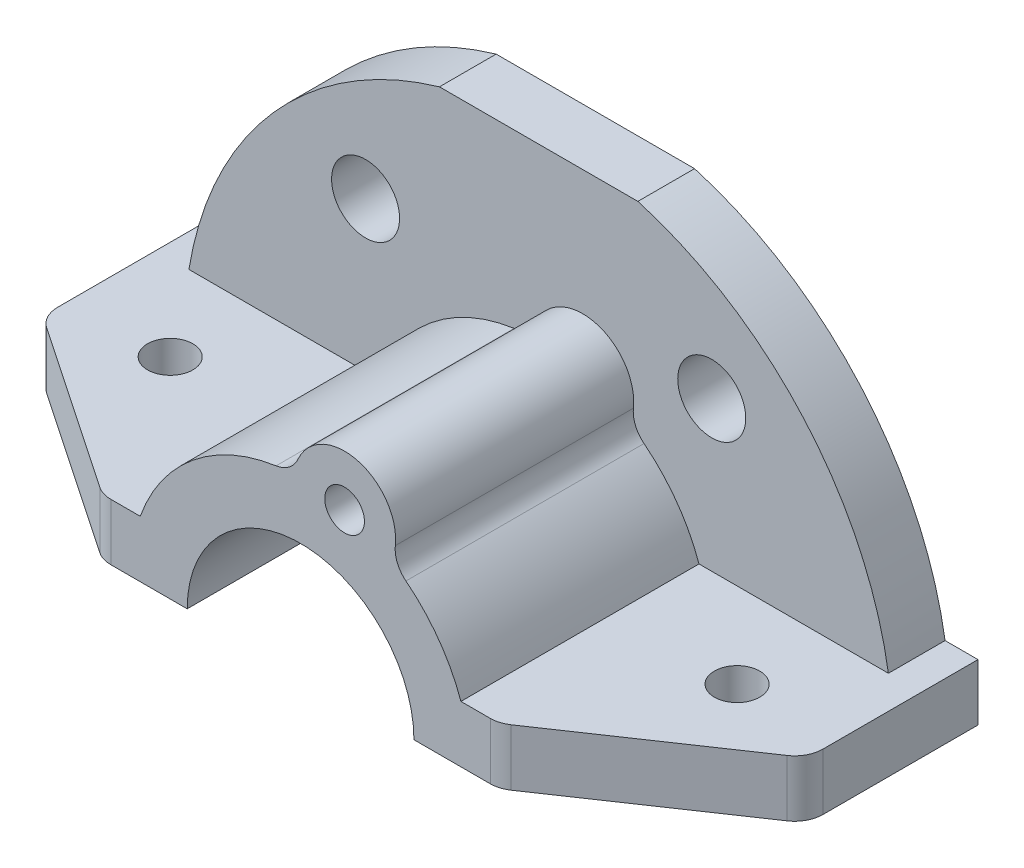
from build123d import *

# Parameters (mm, degrees)
SKETCH2_R           = 4
BOSS_EXTRUDE1_DEPTH = 10
CUT_EXTRUDE1_DEPTH  = 86.791899384
SKETCH3_3_R         = 3.5
BOSS_EXTRUDE2_DEPTH = 52
SKETCH4_R           = 3.5
SKETCH4_R_2         = 6
BOSS_EXTRUDE3_DEPTH = 10
FILLET1_R           = 5


with BuildPart() as part:
    # Sketch2 → Boss-Extrude1 (new body)
    with BuildSketch(Plane(origin=(0, 0, 0), x_dir=(1, 0, 0), z_dir=(0, 1, 0))):
        Polygon((-67.5, 26), (-67.5, -4), (-35, -26), (35, -26), (67.5, -4), (67.5, 26), align=None)
        with Locations(Location((-50, 1, 0), (0, 0, 270))):
            Circle(SKETCH2_R, mode=Mode.SUBTRACT)
        with Locations(Location((50, 1, 0), (0, 0, 270))):
            Circle(SKETCH2_R, mode=Mode.SUBTRACT)
    extrude(amount=BOSS_EXTRUDE1_DEPTH)

    # Sketch3 → Cut-Extrude1 (cut, through all)
    with BuildSketch(Plane.XY.offset(26)):
        with BuildLine():
            Line((20, 0), (0, 0))
            Line((0, 0), (-20, 0))
            ThreePointArc((-20, 0), (0, -20), (20, 0))
        make_face()
        with BuildLine():
            Line((17.320508076, 10), (2.679491924, 10))
            Line((2.679491924, 10), (0, 0))
            Line((0, 0), (20, 0))
            ThreePointArc((20, 0), (19.318516526, 5.176380902), (17.320508076, 10))
        make_face()
        with BuildLine():
            Line((0, 0), (2.679491924, 10))
            Line((2.679491924, 10), (-17.320508076, 10))
            ThreePointArc((-17.320508076, 10), (-19.318516526, 5.176380902), (-20, 0))
            Line((-20, 0), (0, 0))
        make_face()
    extrude(amount=-CUT_EXTRUDE1_DEPTH, mode=Mode.SUBTRACT)


with BuildPart() as cut_extrude1_piece_1:
    # of the separate pieces the step leaves, piece 1, a body of its own (cut_extrude1_pieces)
    add(part.part.solids().sort_by_distance((67.5, 0, -26))[0])



with BuildPart() as cut_extrude1_piece_2:
    # of the separate pieces the step leaves, piece 2, a body of its own (cut_extrude1_pieces)
    add(part.part.solids().sort_by_distance((-67.5, 0, -26))[0])


with BuildPart() as cut_extrude1_piece_1_1:
    add(cut_extrude1_piece_1.part)

    add(cut_extrude1_piece_2.part)  # Boss-Extrude2 merges Cut-Extrude1 piece 2
    # Sketch3_3 → Boss-Extrude2 (add)
    with BuildSketch(Plane.XY.offset(26)):
        with BuildLine():
            ThreePointArc((-17.320508076, 10), (0, 20), (17.320508076, 10))
            Line((17.320508076, 10), (28.284271247, 10))
            ThreePointArc((28.284271247, 10), (23.442777244, 18.719941108), (16.010141687, 25.370758033))
            ThreePointArc((16.010141687, 25.370758033), (10.093942759, 37.671107225), (-1.179810402, 29.976791813))
            ThreePointArc((-1.179810402, 29.976791813), (-17.798906698, 24.149511804), (-28.284271247, 10))
            Line((-28.284271247, 10), (-17.320508076, 10))
        make_face()
        with Locations((7.764571353, 28.977774789)):
            Circle(SKETCH3_3_R, mode=Mode.SUBTRACT)
    extrude(amount=-BOSS_EXTRUDE2_DEPTH)

    # Sketch4 → Boss-Extrude3 (add)
    with BuildSketch(Plane(origin=(0, 0, -26), x_dir=(-1, 0, 0), z_dir=(0, 0, -1))):
        with BuildLine():
            ThreePointArc((62.5, 0), (62.298378138, 5.016181951), (61.694813396, 10))
            Line((61.694813396, 10), (28.284271247, 10))
            ThreePointArc((28.284271247, 10), (17.798906698, 24.149511804), (1.179810402, 29.976791813))
            ThreePointArc((1.179810402, 29.976791813), (-10.093942759, 37.671107225), (-16.010141687, 25.370758033))
            ThreePointArc((-16.010141687, 25.370758033), (-23.442777244, 18.719941108), (-28.284271247, 10))
            Line((-28.284271247, 10), (-61.694813396, 10))
            ThreePointArc((-61.694813396, 10), (-62.298378138, 5.016181951), (-62.5, 0))
            Line((-62.5, 0), (-20, 0))
            ThreePointArc((-20, 0), (0, 20), (20, 0))
            Line((20, 0), (62.5, 0))
        make_face()
        with Locations(Location((-7.764571353, 28.977774789, 0), (0, 0, 180))):
            Circle(SKETCH4_R, mode=Mode.SUBTRACT)
        with BuildLine():
            ThreePointArc((61.694813396, 10), (46.82899334, 41.391972444), (17.5, 60))
            Line((17.5, 60), (-17.5, 60))
            ThreePointArc((-17.5, 60), (-46.82899334, 41.391972444), (-61.694813396, 10))
            Line((-61.694813396, 10), (-28.284271247, 10))
            ThreePointArc((-28.284271247, 10), (-23.442777244, 18.719941108), (-16.010141687, 25.370758033))
            ThreePointArc((-16.010141687, 25.370758033), (-10.093942759, 37.671107225), (1.179810402, 29.976791813))
            ThreePointArc((1.179810402, 29.976791813), (17.798906698, 24.149511804), (28.284271247, 10))
            Line((28.284271247, 10), (61.694813396, 10))
        make_face()
        with Locations((-30.53241146, 36.387111048)):
            Circle(SKETCH4_R_2, mode=Mode.SUBTRACT)
        with Locations((30.53241146, 36.387111048)):
            Circle(SKETCH4_R_2, mode=Mode.SUBTRACT)
    extrude(amount=-BOSS_EXTRUDE3_DEPTH)

    # Fillet1
    fillet1_edges = [cut_extrude1_piece_1_1.edges().sort_by_distance(p)[0] for p in [
        (-35, 5, 26),
        (-67.5, 5, 4),
        (35, 5, 26),
        (67.5, 5, 4),
        (16.010141687, 25.370758033, 5),
        (-1.179810402, 29.976791813, 5),
    ]]
    fillet(fillet1_edges, radius=FILLET1_R)


solid = cut_extrude1_piece_1_1.part
